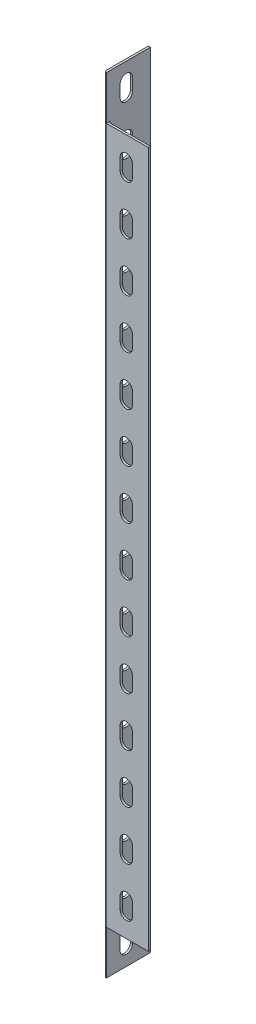
from build123d import *

# Parameters (mm, degrees)
EXTRUDE_THIN1_DEPTH       = 450
FILLET1_R                 = 1.2
CUT_EXTRUDE1_DEPTH        = 26
LPATTERN1_COUNT           = 17
LPATTERN1_PITCH           = 28
CIRPATTERN1_COUNT         = 2
CIRPATTERN1_ANGLE         = 270
CIRPATTERN1_COPY_1_DEPTH  = 26
CIRPATTERN1_COPY_2_DEPTH  = 26
CIRPATTERN1_COPY_3_DEPTH  = 26
CIRPATTERN1_COPY_4_DEPTH  = 26
CIRPATTERN1_COPY_5_DEPTH  = 26
CIRPATTERN1_COPY_6_DEPTH  = 26
CIRPATTERN1_COPY_7_DEPTH  = 26
CIRPATTERN1_COPY_8_DEPTH  = 26
CIRPATTERN1_COPY_9_DEPTH  = 26
CIRPATTERN1_COPY_10_DEPTH = 26
CIRPATTERN1_COPY_11_DEPTH = 26
CIRPATTERN1_COPY_12_DEPTH = 26
CIRPATTERN1_COPY_13_DEPTH = 26
CIRPATTERN1_COPY_14_DEPTH = 26
CIRPATTERN1_COPY_15_DEPTH = 26
CIRPATTERN1_COPY_16_DEPTH = 26
CUT_EXTRUDE2_DEPTH        = 4
SKETCH5_W                 = 23.8
SKETCH5_H                 = 25
CUT_EXTRUDE3_DEPTH        = 10


with BuildPart() as part:
    # Sketch1 → Extrude-Thin1 (new body)
    with BuildSketch(Plane(origin=(0, 0, 0), x_dir=(1, 0, 0), z_dir=(0, 1, 0))):
        Polygon((25, 0), (0, 0), (0, 25), (1.2, 25), (1.2, 1.2), (25, 1.2), align=None)
    extrude(amount=EXTRUDE_THIN1_DEPTH)

    # Fillet1
    fillet1_edges = [part.edges().sort_by_distance(p)[0] for p in [
        (0, 225, 0),
        (1.2, 225, -1.2),
    ]]
    fillet(fillet1_edges, radius=FILLET1_R)

    # Sketch2 → Cut-Extrude1 (cut, through all)
    with BuildSketch(Plane.XY):
        with BuildLine():
            Line((9, 9.5), (9, 16.5))
            ThreePointArc((9, 16.5), (12.5, 20), (16, 16.5))
            Line((16, 16.5), (16, 9.5))
            ThreePointArc((16, 9.5), (12.5, 6), (9, 9.5))
        make_face()
    cut_extrude1 = extrude(amount=-CUT_EXTRUDE1_DEPTH, mode=Mode.SUBTRACT)

    # LPattern1: Cut-Extrude1 ×17
    with Locations(*[(0, i * LPATTERN1_PITCH, 0) for i in range(1, LPATTERN1_COUNT)]):
        add(cut_extrude1, mode=Mode.SUBTRACT)

    # CirPattern1: Cut-Extrude1 ×2 about axis
    cirpattern1_axis = Axis((1.2, 450, 0), (0, -1, 0))
    for i in range(1, CIRPATTERN1_COUNT):
        add(cut_extrude1.rotate(cirpattern1_axis, i * CIRPATTERN1_ANGLE / (CIRPATTERN1_COUNT - 1)), mode=Mode.SUBTRACT)

    # CirPattern1 copy 1 sketch → CirPattern1 copy 1 (cut, through all)
    with BuildSketch(Plane(origin=(1.2, 28, 1.2), x_dir=(0, 0, -1), z_dir=(1, 0, 0))):
        with BuildLine():
            Line((9, 9.5), (9, 16.5))
            ThreePointArc((9, 16.5), (12.5, 20), (16, 16.5))
            Line((16, 16.5), (16, 9.5))
            ThreePointArc((16, 9.5), (12.5, 6), (9, 9.5))
        make_face()
    extrude(amount=-CIRPATTERN1_COPY_1_DEPTH, mode=Mode.SUBTRACT)

    # CirPattern1 copy 2 sketch → CirPattern1 copy 2 (cut, through all)
    with BuildSketch(Plane(origin=(1.2, 56, 1.2), x_dir=(0, 0, -1), z_dir=(1, 0, 0))):
        with BuildLine():
            Line((9, 9.5), (9, 16.5))
            ThreePointArc((9, 16.5), (12.5, 20), (16, 16.5))
            Line((16, 16.5), (16, 9.5))
            ThreePointArc((16, 9.5), (12.5, 6), (9, 9.5))
        make_face()
    extrude(amount=-CIRPATTERN1_COPY_2_DEPTH, mode=Mode.SUBTRACT)

    # CirPattern1 copy 3 sketch → CirPattern1 copy 3 (cut, through all)
    with BuildSketch(Plane(origin=(1.2, 84, 1.2), x_dir=(0, 0, -1), z_dir=(1, 0, 0))):
        with BuildLine():
            Line((9, 9.5), (9, 16.5))
            ThreePointArc((9, 16.5), (12.5, 20), (16, 16.5))
            Line((16, 16.5), (16, 9.5))
            ThreePointArc((16, 9.5), (12.5, 6), (9, 9.5))
        make_face()
    extrude(amount=-CIRPATTERN1_COPY_3_DEPTH, mode=Mode.SUBTRACT)

    # CirPattern1 copy 4 sketch → CirPattern1 copy 4 (cut, through all)
    with BuildSketch(Plane(origin=(1.2, 112, 1.2), x_dir=(0, 0, -1), z_dir=(1, 0, 0))):
        with BuildLine():
            Line((9, 9.5), (9, 16.5))
            ThreePointArc((9, 16.5), (12.5, 20), (16, 16.5))
            Line((16, 16.5), (16, 9.5))
            ThreePointArc((16, 9.5), (12.5, 6), (9, 9.5))
        make_face()
    extrude(amount=-CIRPATTERN1_COPY_4_DEPTH, mode=Mode.SUBTRACT)

    # CirPattern1 copy 5 sketch → CirPattern1 copy 5 (cut, through all)
    with BuildSketch(Plane(origin=(1.2, 140, 1.2), x_dir=(0, 0, -1), z_dir=(1, 0, 0))):
        with BuildLine():
            Line((9, 9.5), (9, 16.5))
            ThreePointArc((9, 16.5), (12.5, 20), (16, 16.5))
            Line((16, 16.5), (16, 9.5))
            ThreePointArc((16, 9.5), (12.5, 6), (9, 9.5))
        make_face()
    extrude(amount=-CIRPATTERN1_COPY_5_DEPTH, mode=Mode.SUBTRACT)

    # CirPattern1 copy 6 sketch → CirPattern1 copy 6 (cut, through all)
    with BuildSketch(Plane(origin=(1.2, 168, 1.2), x_dir=(0, 0, -1), z_dir=(1, 0, 0))):
        with BuildLine():
            Line((9, 9.5), (9, 16.5))
            ThreePointArc((9, 16.5), (12.5, 20), (16, 16.5))
            Line((16, 16.5), (16, 9.5))
            ThreePointArc((16, 9.5), (12.5, 6), (9, 9.5))
        make_face()
    extrude(amount=-CIRPATTERN1_COPY_6_DEPTH, mode=Mode.SUBTRACT)

    # CirPattern1 copy 7 sketch → CirPattern1 copy 7 (cut, through all)
    with BuildSketch(Plane(origin=(1.2, 196, 1.2), x_dir=(0, 0, -1), z_dir=(1, 0, 0))):
        with BuildLine():
            Line((9, 9.5), (9, 16.5))
            ThreePointArc((9, 16.5), (12.5, 20), (16, 16.5))
            Line((16, 16.5), (16, 9.5))
            ThreePointArc((16, 9.5), (12.5, 6), (9, 9.5))
        make_face()
    extrude(amount=-CIRPATTERN1_COPY_7_DEPTH, mode=Mode.SUBTRACT)

    # CirPattern1 copy 8 sketch → CirPattern1 copy 8 (cut, through all)
    with BuildSketch(Plane(origin=(1.2, 224, 1.2), x_dir=(0, 0, -1), z_dir=(1, 0, 0))):
        with BuildLine():
            Line((9, 9.5), (9, 16.5))
            ThreePointArc((9, 16.5), (12.5, 20), (16, 16.5))
            Line((16, 16.5), (16, 9.5))
            ThreePointArc((16, 9.5), (12.5, 6), (9, 9.5))
        make_face()
    extrude(amount=-CIRPATTERN1_COPY_8_DEPTH, mode=Mode.SUBTRACT)

    # CirPattern1 copy 9 sketch → CirPattern1 copy 9 (cut, through all)
    with BuildSketch(Plane(origin=(1.2, 252, 1.2), x_dir=(0, 0, -1), z_dir=(1, 0, 0))):
        with BuildLine():
            Line((9, 9.5), (9, 16.5))
            ThreePointArc((9, 16.5), (12.5, 20), (16, 16.5))
            Line((16, 16.5), (16, 9.5))
            ThreePointArc((16, 9.5), (12.5, 6), (9, 9.5))
        make_face()
    extrude(amount=-CIRPATTERN1_COPY_9_DEPTH, mode=Mode.SUBTRACT)

    # CirPattern1 copy 10 sketch → CirPattern1 copy 10 (cut, through all)
    with BuildSketch(Plane(origin=(1.2, 280, 1.2), x_dir=(0, 0, -1), z_dir=(1, 0, 0))):
        with BuildLine():
            Line((9, 9.5), (9, 16.5))
            ThreePointArc((9, 16.5), (12.5, 20), (16, 16.5))
            Line((16, 16.5), (16, 9.5))
            ThreePointArc((16, 9.5), (12.5, 6), (9, 9.5))
        make_face()
    extrude(amount=-CIRPATTERN1_COPY_10_DEPTH, mode=Mode.SUBTRACT)

    # CirPattern1 copy 11 sketch → CirPattern1 copy 11 (cut, through all)
    with BuildSketch(Plane(origin=(1.2, 308, 1.2), x_dir=(0, 0, -1), z_dir=(1, 0, 0))):
        with BuildLine():
            Line((9, 9.5), (9, 16.5))
            ThreePointArc((9, 16.5), (12.5, 20), (16, 16.5))
            Line((16, 16.5), (16, 9.5))
            ThreePointArc((16, 9.5), (12.5, 6), (9, 9.5))
        make_face()
    extrude(amount=-CIRPATTERN1_COPY_11_DEPTH, mode=Mode.SUBTRACT)

    # CirPattern1 copy 12 sketch → CirPattern1 copy 12 (cut, through all)
    with BuildSketch(Plane(origin=(1.2, 336, 1.2), x_dir=(0, 0, -1), z_dir=(1, 0, 0))):
        with BuildLine():
            Line((9, 9.5), (9, 16.5))
            ThreePointArc((9, 16.5), (12.5, 20), (16, 16.5))
            Line((16, 16.5), (16, 9.5))
            ThreePointArc((16, 9.5), (12.5, 6), (9, 9.5))
        make_face()
    extrude(amount=-CIRPATTERN1_COPY_12_DEPTH, mode=Mode.SUBTRACT)

    # CirPattern1 copy 13 sketch → CirPattern1 copy 13 (cut, through all)
    with BuildSketch(Plane(origin=(1.2, 364, 1.2), x_dir=(0, 0, -1), z_dir=(1, 0, 0))):
        with BuildLine():
            Line((9, 9.5), (9, 16.5))
            ThreePointArc((9, 16.5), (12.5, 20), (16, 16.5))
            Line((16, 16.5), (16, 9.5))
            ThreePointArc((16, 9.5), (12.5, 6), (9, 9.5))
        make_face()
    extrude(amount=-CIRPATTERN1_COPY_13_DEPTH, mode=Mode.SUBTRACT)

    # CirPattern1 copy 14 sketch → CirPattern1 copy 14 (cut, through all)
    with BuildSketch(Plane(origin=(1.2, 392, 1.2), x_dir=(0, 0, -1), z_dir=(1, 0, 0))):
        with BuildLine():
            Line((9, 9.5), (9, 16.5))
            ThreePointArc((9, 16.5), (12.5, 20), (16, 16.5))
            Line((16, 16.5), (16, 9.5))
            ThreePointArc((16, 9.5), (12.5, 6), (9, 9.5))
        make_face()
    extrude(amount=-CIRPATTERN1_COPY_14_DEPTH, mode=Mode.SUBTRACT)

    # CirPattern1 copy 15 sketch → CirPattern1 copy 15 (cut, through all)
    with BuildSketch(Plane(origin=(1.2, 420, 1.2), x_dir=(0, 0, -1), z_dir=(1, 0, 0))):
        with BuildLine():
            Line((9, 9.5), (9, 16.5))
            ThreePointArc((9, 16.5), (12.5, 20), (16, 16.5))
            Line((16, 16.5), (16, 9.5))
            ThreePointArc((16, 9.5), (12.5, 6), (9, 9.5))
        make_face()
    extrude(amount=-CIRPATTERN1_COPY_15_DEPTH, mode=Mode.SUBTRACT)

    # CirPattern1 copy 16 sketch → CirPattern1 copy 16 (cut, through all)
    with BuildSketch(Plane(origin=(1.2, 448, 1.2), x_dir=(0, 0, -1), z_dir=(1, 0, 0))):
        with BuildLine():
            Line((9, 9.5), (9, 16.5))
            ThreePointArc((9, 16.5), (12.5, 20), (16, 16.5))
            Line((16, 16.5), (16, 9.5))
            ThreePointArc((16, 9.5), (12.5, 6), (9, 9.5))
        make_face()
    extrude(amount=-CIRPATTERN1_COPY_16_DEPTH, mode=Mode.SUBTRACT)

    # Sketch3 → Cut-Extrude2 (cut)
    with BuildSketch(Plane(origin=(0, 450, 0), x_dir=(1, 0, 0), z_dir=(0, 1, 0))):
        with BuildLine():
            Line((0, 25), (0, 1.2))
            ThreePointArc((0, 1.2), (0.351471863, 0.351471863), (1.2, 0))
            Line((1.2, 0), (25, 0))
            Line((25, 0), (25, 1.2))
            Line((25, 1.2), (2.4, 1.2))
            ThreePointArc((2.4, 1.2), (1.551471863, 1.551471863), (1.2, 2.4))
            Line((1.2, 2.4), (1.2, 25))
            Line((1.2, 25), (0, 25))
        make_face()
    extrude(amount=-CUT_EXTRUDE2_DEPTH, mode=Mode.SUBTRACT)

    # Sketch5 → Cut-Extrude3 (cut)
    with BuildSketch(Plane.XY):
        with Locations((13.1, 433.5)):
            Rectangle(SKETCH5_W, SKETCH5_H)
        with Locations((13.1, 12.5)):
            Rectangle(SKETCH5_W, SKETCH5_H)
    extrude(amount=-CUT_EXTRUDE3_DEPTH, mode=Mode.SUBTRACT)


solid = part.part
